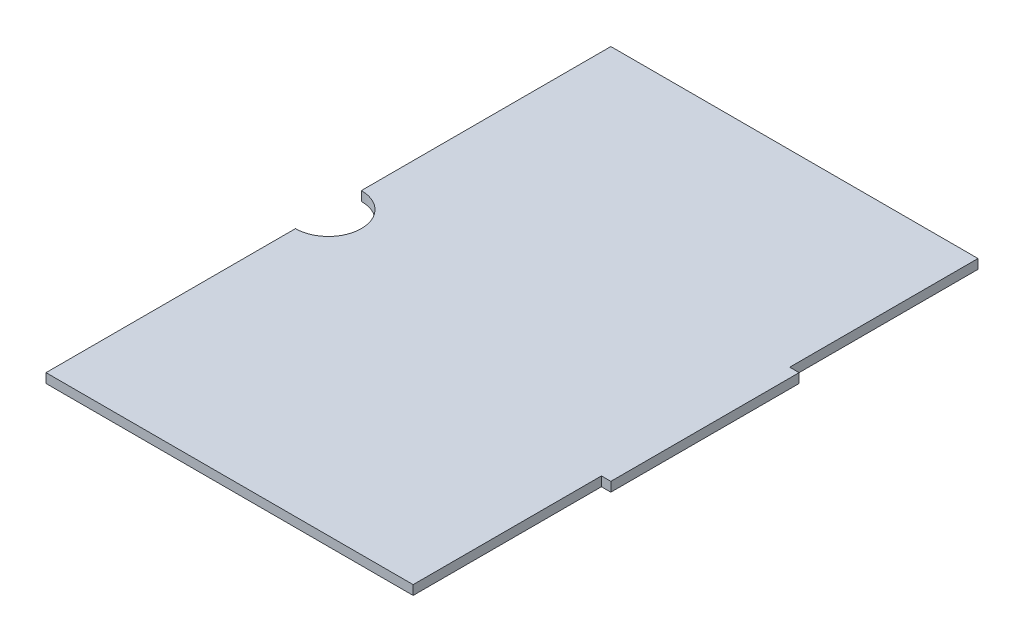
from build123d import *

# Parameters (mm, degrees)
BOSS_EXTRUDE2_DEPTH = 3


with BuildPart() as part:
    # Sketch1 → Boss-Extrude2 (new body)
    with BuildSketch(Plane(origin=(0, 0, 0), x_dir=(1, 0, 0), z_dir=(0, 1, 0))):
        with BuildLine():
            Line((-60, -10.5), (-60, -90))
            Line((-60, -90), (57, -90))
            Line((57, -90), (57, -30))
            Line((57, -30), (60, -30))
            Line((60, -30), (60, 30))
            Line((60, 30), (57, 30))
            Line((57, 30), (57, 90))
            Line((57, 90), (-60, 90))
            Line((-60, 90), (-60, 10.5))
            ThreePointArc((-60, 10.5), (-49.5, 0), (-60, -10.5))
        make_face()
    extrude(amount=BOSS_EXTRUDE2_DEPTH)


solid = part.part
